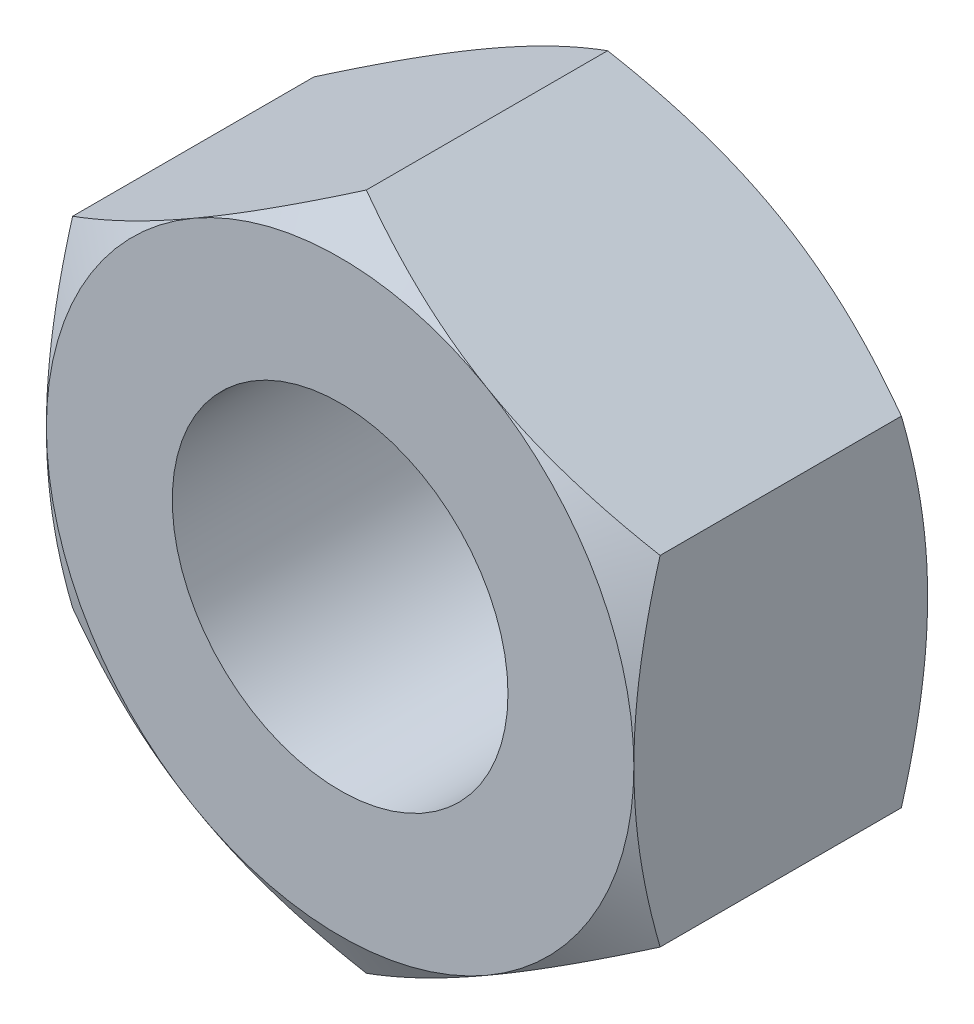
from build123d import *

# Parameters (mm, degrees)
SKETCH1_R               = 3.175
EXTRUDE1_DEPTH          = 2.778125
SKETCH7_OUTSIDE_W       = 104.672
SKETCH7_OUTSIDE_H       = 106.392
SKETCH7_OUTSIDE_R       = 5.55625
EXTRUDE2_DEPTH          = 25.4
EXTRUDE2_DRAFT          = -60
MIRROR1_COPY_1_SKETCH_W = 104.672
MIRROR1_COPY_1_SKETCH_H = 106.392
MIRROR1_COPY_1_SKETCH_R = 5.55625
MIRROR1_COPY_1_DEPTH    = 25.4
MIRROR1_COPY_1_DRAFT    = -60


with BuildPart() as part:
    # Sketch1 → Extrude1 (new, symmetric)
    with BuildSketch(Plane.XY):
        Polygon((-5.55625, 3.207902433), (-5.55625, -3.207902433), (0, -6.415804866), (5.55625, -3.207902433), (5.55625, 3.207902433), (0, 6.415804866), align=None)
        Circle(SKETCH1_R, mode=Mode.SUBTRACT)
    extrude(amount=EXTRUDE1_DEPTH, both=True)


with BuildPart() as extrude2_tool:
    # Sketch7 outside → Extrude2 (with draft: the straight prism first)
    with BuildSketch(Plane.XY.offset(2.778125)):
        Rectangle(SKETCH7_OUTSIDE_W, SKETCH7_OUTSIDE_H)
        Circle(SKETCH7_OUTSIDE_R, mode=Mode.SUBTRACT)
    extrude(amount=-EXTRUDE2_DEPTH)
    # Extrude2: the draft: its side faces are tilted about the plane it starts from
    extrude2_sides = [extrude2_tool.faces().sort_by_distance(p)[0] for p in [
        (0, -53.196, -9.921875),
        (52.336, 0, -9.921875),
        (0, 53.196, -9.921875),
        (-52.336, 0, -9.921875),
        (-5.55625, 0, -9.921875),
    ]]
    draft(extrude2_sides, Plane.XY.offset(2.778125), EXTRUDE2_DRAFT)


with BuildPart() as part_1:
    add(part.part)

    # Extrude2: cut by extrude2_tool
    add(extrude2_tool.part, mode=Mode.SUBTRACT)


with BuildPart() as mirror1_copy_1_tool:
    # Mirror1 copy 1 sketch → Mirror1 copy 1 (with draft: the straight prism first)
    with BuildSketch(Plane(origin=(0, 0, -2.778125), x_dir=(1, 0, 0), z_dir=(0, 0, -1))):
        Rectangle(MIRROR1_COPY_1_SKETCH_W, MIRROR1_COPY_1_SKETCH_H)
        Circle(MIRROR1_COPY_1_SKETCH_R, mode=Mode.SUBTRACT)
    extrude(amount=-MIRROR1_COPY_1_DEPTH)
    # Mirror1 copy 1: the draft: its side faces are tilted about the plane it starts from
    mirror1_copy_1_sides = [mirror1_copy_1_tool.faces().sort_by_distance(p)[0] for p in [
        (0, -53.196, 9.921875),
        (52.336, 0, 9.921875),
        (0, 53.196, 9.921875),
        (-52.336, 0, 9.921875),
        (-5.55625, 0, 9.921875),
    ]]
    draft(mirror1_copy_1_sides, Plane(origin=(0, 0, -2.778125), x_dir=(1, 0, 0), z_dir=(0, 0, -1)), MIRROR1_COPY_1_DRAFT)


with BuildPart() as part_2:
    add(part_1.part)

    # Mirror1 copy 1: cut by mirror1_copy_1_tool
    add(mirror1_copy_1_tool.part, mode=Mode.SUBTRACT)


solid = part_2.part
